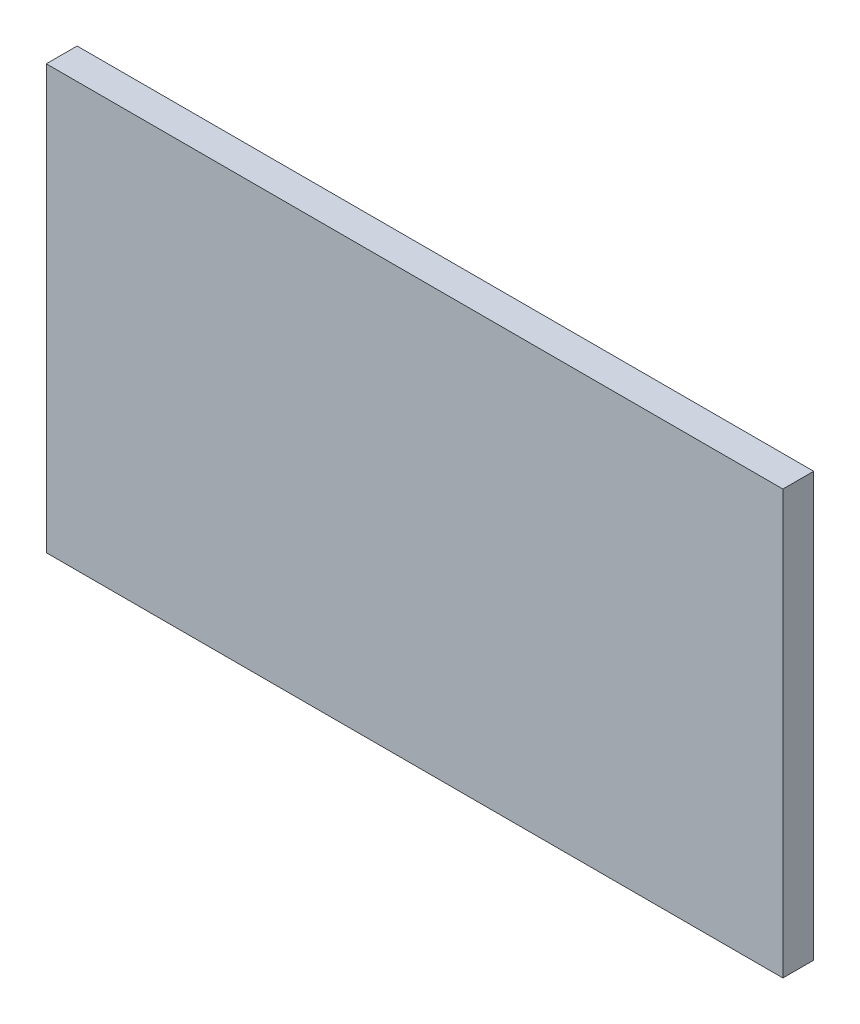
from build123d import *

# Parameters (mm, degrees)
SKETCH1_W           = 1457.96
SKETCH1_H           = 838.2
BOSS_EXTRUDE1_DEPTH = 60.96


with BuildPart() as part:
    # Sketch1 → Boss-Extrude1 (new body)
    with BuildSketch(Plane.XY):
        with Locations((-1733.137880795, 11.160860927)):
            Rectangle(SKETCH1_W, SKETCH1_H)
    extrude(amount=BOSS_EXTRUDE1_DEPTH)


solid = part.part
